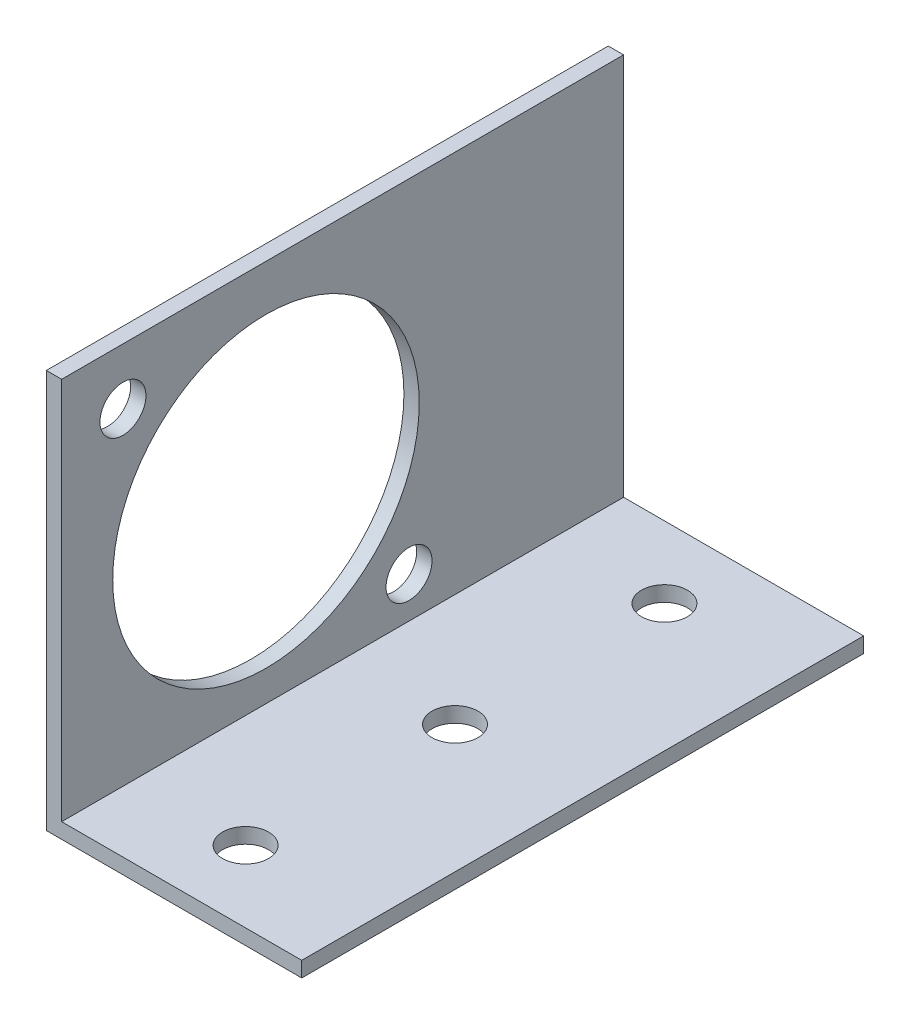
from build123d import *

# Parameters (mm, degrees)
EXTRU_MINCE1_DEPTH    = 55
D_GAGEMENT_M41_D      = 4.5
D_GAGEMENT_M42_D      = 4.5
D_GAGEMENT_M271_D     = 30
D_GAGEMENT_M271_DEPTH = 1.5
D_GAGEMENT_M271_TIP   = 9.012909285


with BuildPart() as part:
    # Esquisse1 → Extru.-Mince1 (new body)
    with BuildSketch(Plane.XY):
        Polygon((0, 39), (0, 0), (25, 0), (25, 1.5), (1.5, 1.5), (1.5, 39), align=None)
    extrude(amount=-EXTRU_MINCE1_DEPTH)

    # Dégagement M41 (through all)
    with Locations(Plane(origin=(0, 1.5, 0), x_dir=(-1, 0, 0), z_dir=(0, 1, 0))):
        with Locations((-12.5, -7), (-12.5, -27.5), (-12.5, -48)):
            Hole(D_GAGEMENT_M41_D / 2)

    # Dégagement M42 (through all)
    with Locations(Plane(origin=(1.5, 0, 0), x_dir=(0, 0, -1), z_dir=(1, 0, 0))):
        with Locations((6, 33.5), (34, 5.5)):
            Hole(D_GAGEMENT_M42_D / 2)

    # Dégagement M271
    with Locations(Plane(origin=(1.5, 0, 0), x_dir=(0, 0, -1), z_dir=(1, 0, 0))):
        with Locations((20, 19.5)):
            Hole(D_GAGEMENT_M271_D / 2, depth=D_GAGEMENT_M271_DEPTH)
            with Locations((0, 0, -(D_GAGEMENT_M271_DEPTH + D_GAGEMENT_M271_TIP / 2))):  # 118° drill point
                Cone(0, D_GAGEMENT_M271_D / 2, D_GAGEMENT_M271_TIP, mode=Mode.SUBTRACT)


solid = part.part
